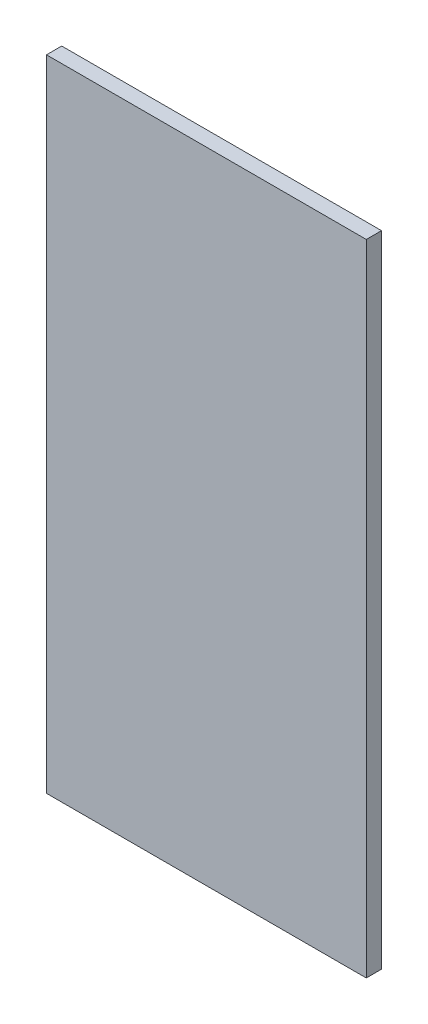
from build123d import *

# Parameters (mm, degrees)
SKETCH1_W           = 53.34
SKETCH1_H           = 106.68
BOSS_EXTRUDE2_DEPTH = 1.27


with BuildPart() as part:
    # Sketch1 → Boss-Extrude2 (new body, symmetric)
    with BuildSketch(Plane.XY):
        Rectangle(SKETCH1_W, SKETCH1_H)
    extrude(amount=BOSS_EXTRUDE2_DEPTH, both=True)


solid = part.part
